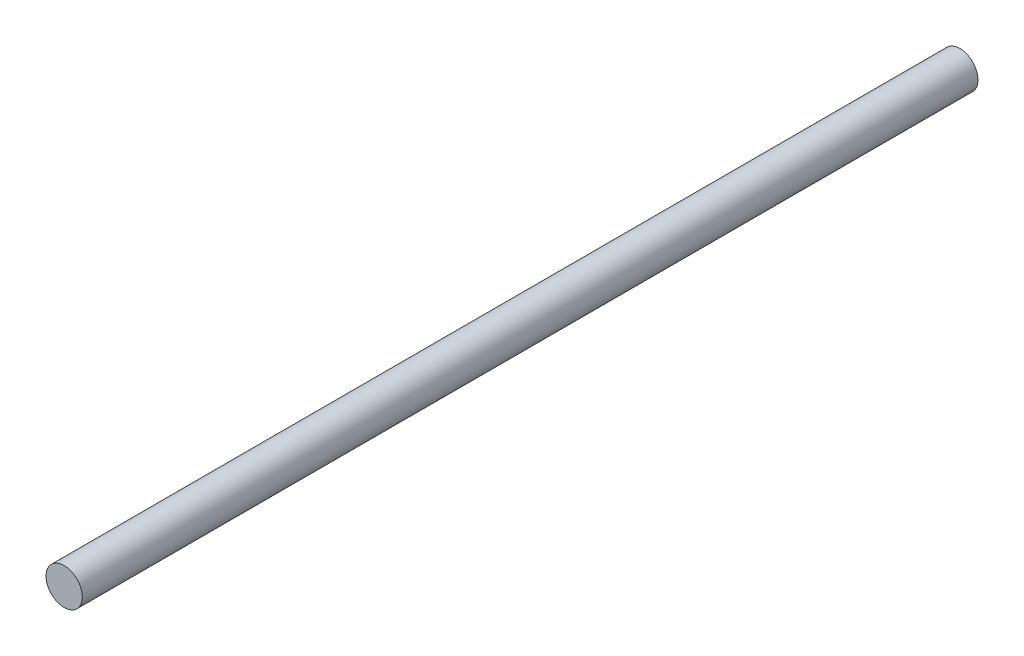
from build123d import *

# Parameters (mm, degrees)
SKETCH1_R           = 1.5
BOSS_EXTRUDE1_DEPTH = 74


with BuildPart() as part:
    # Sketch1 → Boss-Extrude1 (new body)
    with BuildSketch(Plane.XY):
        Circle(SKETCH1_R)
    extrude(amount=BOSS_EXTRUDE1_DEPTH)


solid = part.part
